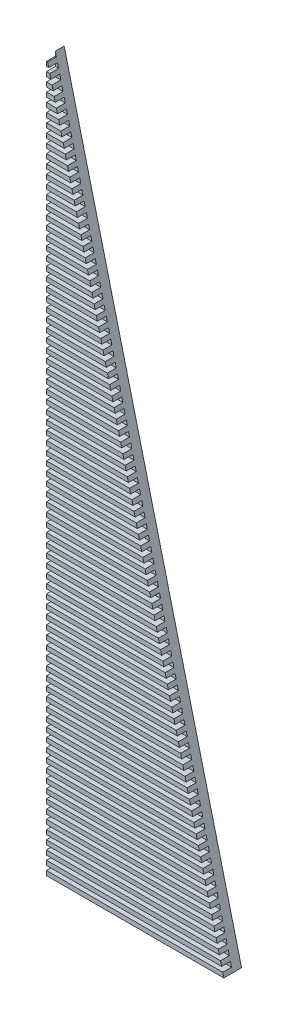
from build123d import *

# Parameters (mm, degrees)
BOSS_EXTRUDE4_DEPTH = 2
BOSS_EXTRUDE6_DEPTH = 2


with BuildPart() as part:
    # Sketch2 → Boss-Extrude4 (new body)
    with BuildSketch(Plane.XY):
        Polygon((-53.141538462, -19.555384615), (-13.141538462, -19.555384615), (-53.141538462, 140.444615385), align=None)
    extrude(amount=BOSS_EXTRUDE4_DEPTH)

    # Sketch4 → Boss-Extrude6 (add)
    with BuildSketch(Plane.XY.offset(2)):
        Polygon((-53.141538462, -18.555384615), (-53.141538462, -19.555384615), (-13.141538462, -19.555384615), (-13.391538462, -18.555384615), align=None)
        Polygon((-53.141538462, -16.555384615), (-53.141538462, -17.555384615), (-13.641538462, -17.555384615), (-13.891538462, -16.555384615), align=None)
        Polygon((-53.141538462, -14.555384615), (-53.141538462, -15.555384615), (-14.141538462, -15.555384615), (-14.391538462, -14.555384615), align=None)
        Polygon((-53.141538462, -12.555384615), (-53.141538462, -13.555384615), (-14.641538462, -13.555384615), (-14.891538462, -12.555384615), align=None)
        Polygon((-53.141538462, -10.555384615), (-53.141538462, -11.555384615), (-15.141538462, -11.555384615), (-15.391538462, -10.555384615), align=None)
        Polygon((-53.141538462, -8.555384615), (-53.141538462, -9.555384615), (-15.641538462, -9.555384615), (-15.891538462, -8.555384615), align=None)
        Polygon((-53.141538462, -6.555384615), (-53.141538462, -7.555384615), (-16.141538462, -7.555384615), (-16.391538462, -6.555384615), align=None)
        Polygon((-53.141538462, -4.555384615), (-53.141538462, -5.555384615), (-16.641538462, -5.555384615), (-16.891538462, -4.555384615), align=None)
        Polygon((-53.141538462, -2.555384615), (-53.141538462, -3.555384615), (-17.141538462, -3.555384615), (-17.391538462, -2.555384615), align=None)
        Polygon((-53.141538462, -0.555384615), (-53.141538462, -1.555384615), (-17.641538462, -1.555384615), (-17.891538462, -0.555384615), align=None)
        Polygon((-53.141538462, 1.444615385), (-53.141538462, 0.444615385), (-18.141538462, 0.444615385), (-18.391538462, 1.444615385), align=None)
        Polygon((-53.141538462, 3.444615385), (-53.141538462, 2.444615385), (-18.641538462, 2.444615385), (-18.891538462, 3.444615385), align=None)
        Polygon((-53.141538462, 5.444615385), (-53.141538462, 4.444615385), (-19.141538462, 4.444615385), (-19.391538462, 5.444615385), align=None)
        Polygon((-53.141538462, 7.444615385), (-53.141538462, 6.444615385), (-19.641538462, 6.444615385), (-19.891538462, 7.444615385), align=None)
        Polygon((-53.141538462, 9.444615385), (-53.141538462, 8.444615385), (-20.141538462, 8.444615385), (-20.391538462, 9.444615385), align=None)
        Polygon((-53.141538462, 11.444615385), (-53.141538462, 10.444615385), (-20.641538462, 10.444615385), (-20.891538462, 11.444615385), align=None)
        Polygon((-53.141538462, 13.444615385), (-53.141538462, 12.444615385), (-21.141538462, 12.444615385), (-21.391538462, 13.444615385), align=None)
        Polygon((-53.141538462, 15.444615385), (-53.141538462, 14.444615385), (-21.641538462, 14.444615385), (-21.891538462, 15.444615385), align=None)
        Polygon((-53.141538462, 17.444615385), (-53.141538462, 16.444615385), (-22.141538462, 16.444615385), (-22.391538462, 17.444615385), align=None)
        Polygon((-53.141538462, 19.444615385), (-53.141538462, 18.444615385), (-22.641538462, 18.444615385), (-22.891538462, 19.444615385), align=None)
        Polygon((-53.141538462, 21.444615385), (-53.141538462, 20.444615385), (-23.141538462, 20.444615385), (-23.391538462, 21.444615385), align=None)
        Polygon((-53.141538462, 23.444615385), (-53.141538462, 22.444615385), (-23.641538462, 22.444615385), (-23.891538462, 23.444615385), align=None)
        Polygon((-53.141538462, 25.444615385), (-53.141538462, 24.444615385), (-24.141538462, 24.444615385), (-24.391538462, 25.444615385), align=None)
        Polygon((-53.141538462, 27.444615385), (-53.141538462, 26.444615385), (-24.641538462, 26.444615385), (-24.891538462, 27.444615385), align=None)
        Polygon((-53.141538462, 29.444615385), (-53.141538462, 28.444615385), (-25.141538462, 28.444615385), (-25.391538462, 29.444615385), align=None)
        Polygon((-53.141538462, 31.444615385), (-53.141538462, 30.444615385), (-25.641538462, 30.444615385), (-25.891538462, 31.444615385), align=None)
        Polygon((-53.141538462, 33.444615385), (-53.141538462, 32.444615385), (-26.141538462, 32.444615385), (-26.391538462, 33.444615385), align=None)
        Polygon((-53.141538462, 35.444615385), (-53.141538462, 34.444615385), (-26.641538462, 34.444615385), (-26.891538462, 35.444615385), align=None)
        Polygon((-53.141538462, 37.444615385), (-53.141538462, 36.444615385), (-27.141538462, 36.444615385), (-27.391538462, 37.444615385), align=None)
        Polygon((-53.141538462, 39.444615385), (-53.141538462, 38.444615385), (-27.641538462, 38.444615385), (-27.891538462, 39.444615385), align=None)
        Polygon((-53.141538462, 41.444615385), (-53.141538462, 40.444615385), (-28.141538462, 40.444615385), (-28.391538462, 41.444615385), align=None)
        Polygon((-53.141538462, 43.444615385), (-53.141538462, 42.444615385), (-28.641538462, 42.444615385), (-28.891538462, 43.444615385), align=None)
        Polygon((-53.141538462, 45.444615385), (-53.141538462, 44.444615385), (-29.141538462, 44.444615385), (-29.391538462, 45.444615385), align=None)
        Polygon((-53.141538462, 47.444615385), (-53.141538462, 46.444615385), (-29.641538462, 46.444615385), (-29.891538462, 47.444615385), align=None)
        Polygon((-53.141538462, 49.444615385), (-53.141538462, 48.444615385), (-30.141538462, 48.444615385), (-30.391538462, 49.444615385), align=None)
        Polygon((-53.141538462, 51.444615385), (-53.141538462, 50.444615385), (-30.641538462, 50.444615385), (-30.891538462, 51.444615385), align=None)
        Polygon((-53.141538462, 53.444615385), (-53.141538462, 52.444615385), (-31.141538462, 52.444615385), (-31.391538462, 53.444615385), align=None)
        Polygon((-53.141538462, 55.444615385), (-53.141538462, 54.444615385), (-31.641538462, 54.444615385), (-31.891538462, 55.444615385), align=None)
        Polygon((-53.141538462, 57.444615385), (-53.141538462, 56.444615385), (-32.141538462, 56.444615385), (-32.391538462, 57.444615385), align=None)
        Polygon((-53.141538462, 59.444615385), (-53.141538462, 58.444615385), (-32.641538462, 58.444615385), (-32.891538462, 59.444615385), align=None)
        Polygon((-53.141538462, 61.444615385), (-53.141538462, 60.444615385), (-33.141538462, 60.444615385), (-33.391538462, 61.444615385), align=None)
        Polygon((-53.141538462, 63.444615385), (-53.141538462, 62.444615385), (-33.641538462, 62.444615385), (-33.891538462, 63.444615385), align=None)
        Polygon((-53.141538462, 65.444615385), (-53.141538462, 64.444615385), (-34.141538462, 64.444615385), (-34.391538462, 65.444615385), align=None)
        Polygon((-53.141538462, 67.444615385), (-53.141538462, 66.444615385), (-34.641538462, 66.444615385), (-34.891538462, 67.444615385), align=None)
        Polygon((-53.141538462, 69.444615385), (-53.141538462, 68.444615385), (-35.141538462, 68.444615385), (-35.391538462, 69.444615385), align=None)
        Polygon((-53.141538462, 71.444615385), (-53.141538462, 70.444615385), (-35.641538462, 70.444615385), (-35.891538462, 71.444615385), align=None)
        Polygon((-53.141538462, 73.444615385), (-53.141538462, 72.444615385), (-36.141538462, 72.444615385), (-36.391538462, 73.444615385), align=None)
        Polygon((-53.141538462, 75.444615385), (-53.141538462, 74.444615385), (-36.641538462, 74.444615385), (-36.891538462, 75.444615385), align=None)
        Polygon((-53.141538462, 77.444615385), (-53.141538462, 76.444615385), (-37.141538462, 76.444615385), (-37.391538462, 77.444615385), align=None)
        Polygon((-53.141538462, 79.444615385), (-53.141538462, 78.444615385), (-37.641538462, 78.444615385), (-37.891538462, 79.444615385), align=None)
        Polygon((-53.141538462, 81.444615385), (-53.141538462, 80.444615385), (-38.141538462, 80.444615385), (-38.391538462, 81.444615385), align=None)
        Polygon((-53.141538462, 83.444615385), (-53.141538462, 82.444615385), (-38.641538462, 82.444615385), (-38.891538462, 83.444615385), align=None)
        Polygon((-53.141538462, 85.444615385), (-53.141538462, 84.444615385), (-39.141538462, 84.444615385), (-39.391538462, 85.444615385), align=None)
        Polygon((-53.141538462, 87.444615385), (-53.141538462, 86.444615385), (-39.641538462, 86.444615385), (-39.891538462, 87.444615385), align=None)
        Polygon((-53.141538462, 89.444615385), (-53.141538462, 88.444615385), (-40.141538462, 88.444615385), (-40.391538462, 89.444615385), align=None)
        Polygon((-53.141538462, 91.444615385), (-53.141538462, 90.444615385), (-40.641538462, 90.444615385), (-40.891538462, 91.444615385), align=None)
        Polygon((-53.141538462, 93.444615385), (-53.141538462, 92.444615385), (-41.141538462, 92.444615385), (-41.391538462, 93.444615385), align=None)
        Polygon((-53.141538462, 95.444615385), (-53.141538462, 94.444615385), (-41.641538462, 94.444615385), (-41.891538462, 95.444615385), align=None)
        Polygon((-53.141538462, 97.444615385), (-53.141538462, 96.444615385), (-42.141538462, 96.444615385), (-42.391538462, 97.444615385), align=None)
        Polygon((-53.141538462, 99.444615385), (-53.141538462, 98.444615385), (-42.641538462, 98.444615385), (-42.891538462, 99.444615385), align=None)
        Polygon((-53.141538462, 101.444615385), (-53.141538462, 100.444615385), (-43.141538462, 100.444615385), (-43.391538462, 101.444615385), align=None)
        Polygon((-53.141538462, 103.444615385), (-53.141538462, 102.444615385), (-43.641538462, 102.444615385), (-43.891538462, 103.444615385), align=None)
        Polygon((-53.141538462, 105.444615385), (-53.141538462, 104.444615385), (-44.141538462, 104.444615385), (-44.391538462, 105.444615385), align=None)
        Polygon((-53.141538462, 107.444615385), (-53.141538462, 106.444615385), (-44.641538462, 106.444615385), (-44.891538462, 107.444615385), align=None)
        Polygon((-53.141538462, 109.444615385), (-53.141538462, 108.444615385), (-45.141538462, 108.444615385), (-45.391538462, 109.444615385), align=None)
        Polygon((-53.141538462, 111.444615385), (-53.141538462, 110.444615385), (-45.641538462, 110.444615385), (-45.891538462, 111.444615385), align=None)
        Polygon((-53.141538462, 113.444615385), (-53.141538462, 112.444615385), (-46.141538462, 112.444615385), (-46.391538462, 113.444615385), align=None)
        Polygon((-53.141538462, 115.444615385), (-53.141538462, 114.444615385), (-46.641538462, 114.444615385), (-46.891538462, 115.444615385), align=None)
        Polygon((-53.141538462, 117.444615385), (-53.141538462, 116.444615385), (-47.141538462, 116.444615385), (-47.391538462, 117.444615385), align=None)
        Polygon((-53.141538462, 119.444615385), (-53.141538462, 118.444615385), (-47.641538462, 118.444615385), (-47.891538462, 119.444615385), align=None)
        Polygon((-53.141538462, 121.444615385), (-53.141538462, 120.444615385), (-48.141538462, 120.444615385), (-48.391538462, 121.444615385), align=None)
        Polygon((-53.141538462, 123.444615385), (-53.141538462, 122.444615385), (-48.641538462, 122.444615385), (-48.891538462, 123.444615385), align=None)
        Polygon((-53.141538462, 125.444615385), (-53.141538462, 124.444615385), (-49.141538462, 124.444615385), (-49.391538462, 125.444615385), align=None)
        Polygon((-53.141538462, 127.444615385), (-53.141538462, 126.444615385), (-49.641538462, 126.444615385), (-49.891538462, 127.444615385), align=None)
        Polygon((-53.141538462, 129.444615385), (-53.141538462, 128.444615385), (-50.141538462, 128.444615385), (-50.391538462, 129.444615385), align=None)
        Polygon((-53.141538462, 131.444615385), (-53.141538462, 130.444615385), (-50.641538462, 130.444615385), (-50.891538462, 131.444615385), align=None)
        Polygon((-53.141538462, 133.444615385), (-53.141538462, 132.444615385), (-51.141538462, 132.444615385), (-51.391538462, 133.444615385), align=None)
        Polygon((-53.141538462, 135.444615385), (-53.141538462, 134.444615385), (-51.641538462, 134.444615385), (-51.891538462, 135.444615385), align=None)
        Polygon((-53.141538462, 137.444615385), (-53.141538462, 136.444615385), (-52.141538462, 136.444615385), (-52.391538462, 137.444615385), align=None)
        Polygon((-53.141538462, 139.444615385), (-53.141538462, 138.444615385), (-52.641538462, 138.444615385), (-52.891538462, 139.444615385), align=None)
    extrude(amount=BOSS_EXTRUDE6_DEPTH)


solid = part.part
